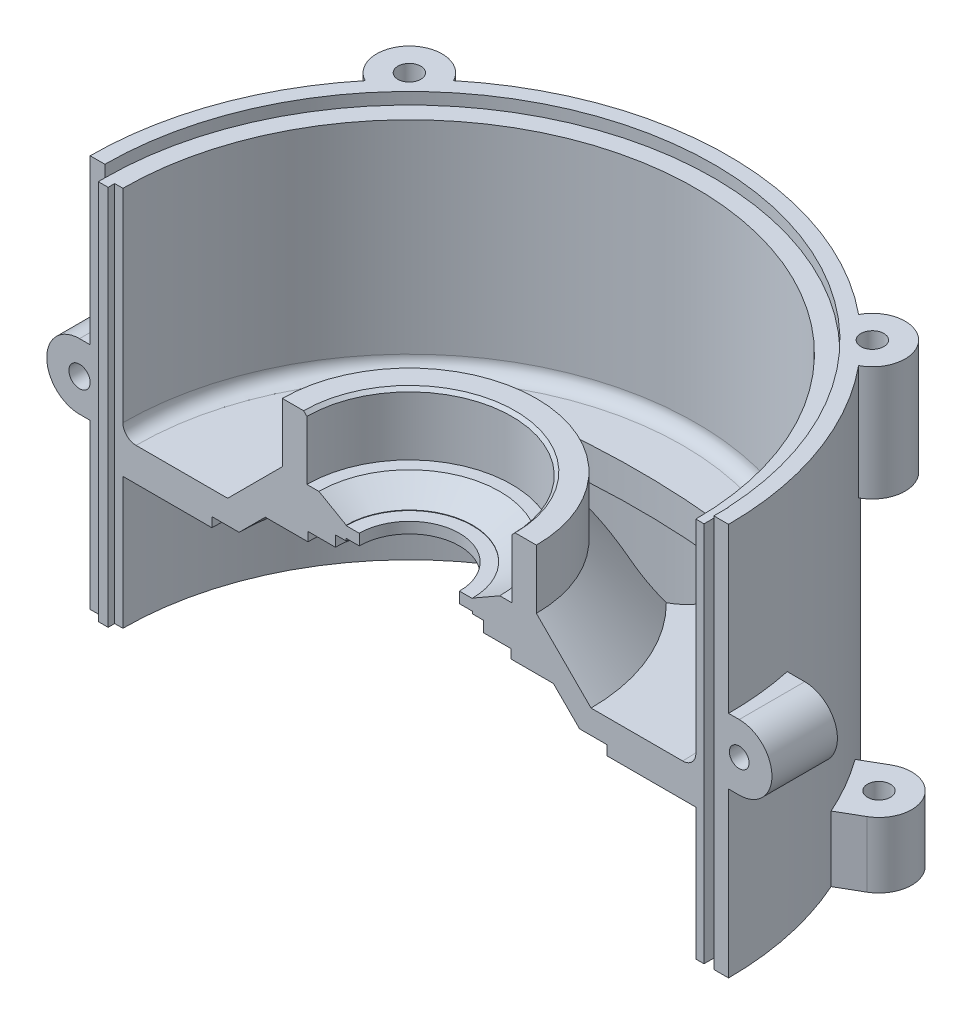
from build123d import *

# Parameters (mm, degrees)
REVOLU_O2_ANGLE          = 180
ESBO_O4_R                = 10
RESSALTO_EXTRUS_O1_DEPTH = 35
RESSALTO_EXTRUS_O2_DEPTH = 20
ESBO_O8_R                = 3.5
CORTE_EXTRUS_O2_DEPTH    = 20
PADR_OCIRCULAR1_COUNT    = 6
ESBO_O6_R                = 3.5
CORTE_EXTRUS_O1_DEPTH    = 15
ESBO_O9_R                = 1.25
CORTE_EXTRUS_O3_DEPTH    = 6
ESBO_O10_W               = 3
ESBO_O10_H               = 120
CORTE_EXTRUS_O4_DEPTH    = 4.5
ESBO_O11_W               = 3
ESBO_O11_H               = 116.4
RESSALTO_EXTRUS_O5_DEPTH = 2
ESBO_O12_R               = 3.25
RESSALTO_EXTRUS_O6_DEPTH = 20
ESBO_O13_R               = 3
RESSALTO_EXTRUS_O7_DEPTH = 20
CORTE_EXTRUS_O5_DEPTH    = 80.8
ESBO_O16_R               = 93
CORTE_EXTRUS_O6_DEPTH    = 10


with BuildPart() as part:
    # Esboço3 → Revolução2 (revolve)
    with BuildSketch(Plane.XY):
        with BuildLine():
            Line((97.5, 79.8), (97.5, 11.304491341))
            Line((97.5, 11.304491341), (97.5, 0))
            Line((97.5, 0), (97.5, -40.2))
            Line((97.5, -40.2), (87.5, -40.2))
            Line((87.5, -40.2), (87.5, 0))
            Line((87.5, 0), (60.342408243, 0))
            Line((60.342408243, 0), (60.342408243, 2.95))
            Line((60.342408243, 2.95), (52, 2.95))
            Line((52, 2.95), (44, 10.95))
            Line((44, 10.95), (31, 10.95))
            Line((31, 10.95), (31, 13.7))
            Line((31, 13.7), (22.6, 13.7))
            Line((22.6, 13.7), (22.6, 17))
            Line((22.6, 17), (19.3, 17))
            Line((19.3, 17), (19.3, 17.7))
            Line((19.3, 17.7), (15.3, 17.7))
            Line((15.3, 17.7), (15.3, 21.05))
            Line((15.3, 21.05), (19.3, 21.05))
            Line((19.3, 21.05), (19.3, 21.2))
            Line((19.3, 21.2), (27.626549127, 25.96))
            Line((27.626549127, 25.96), (31.3, 25.96))
            Line((31.3, 25.96), (31.3, 43.96))
            Line((31.3, 43.96), (32.3, 44.96))
            Line((32.3, 44.96), (38.8, 44.96))
            Line((38.8, 44.96), (38.8, 26.9))
            Line((38.8, 26.9), (55.5, 10.2))
            Line((55.5, 10.2), (83.5, 10.2))
            ThreePointArc((83.5, 10.2), (86.328427125, 11.371572875), (87.5, 14.2))
            Line((87.5, 14.2), (87.5, 76.2))
            Line((87.5, 76.2), (93, 76.2))
            Line((93, 76.2), (93, 79.8))
            Line((93, 79.8), (97.5, 79.8))
        make_face()
    revolve(axis=Axis((0, -3.322055656, 0), (0, 1, 0)), revolution_arc=REVOLU_O2_ANGLE)

    # Esboço4 → Ressalto-extrusão1 (add)
    with BuildSketch(Plane(origin=(0, 79.8, 0), x_dir=(1, 0, 0), z_dir=(0, 1, 0))):
        with Locations((70.71, 70.71)):
            Circle(ESBO_O4_R)
        with Locations((-70.71, 70.71)):
            Circle(ESBO_O4_R)
    extrude(amount=-RESSALTO_EXTRUS_O1_DEPTH)

    # Esboço5 → Ressalto-extrusão2 (add)
    with BuildSketch(Plane.XZ.offset(40.2)):
        with BuildLine():
            Line((10, -105), (10, -96.985823706))
            Line((10, -96.985823706), (-10, -96.985823706))
            Line((-10, -96.985823706), (-10, -105))
            ThreePointArc((-10, -105), (0, -115), (10, -105))
        make_face()
    ressalto_extrus_o2 = extrude(amount=-RESSALTO_EXTRUS_O2_DEPTH)

    # Esboço8 → Corte-extrusão2 (cut)
    with BuildSketch(Plane.XZ.offset(40.2)):
        with Locations((0, -105)):
            Circle(ESBO_O8_R)
    corte_extrus_o2 = extrude(amount=-CORTE_EXTRUS_O2_DEPTH, mode=Mode.SUBTRACT)

    # PadrãoCircular1: Ressalto-extrusão2, Corte-extrusão2 ×6 about axis, 3 skipped
    padr_ocircular1_axis = Axis((0, 0, 0), (0, 1, 0))
    add([ressalto_extrus_o2.rotate(padr_ocircular1_axis, i * 360 / PADR_OCIRCULAR1_COUNT) for i in range(1, PADR_OCIRCULAR1_COUNT) if i not in (2, 3, 4)])
    add([corte_extrus_o2.rotate(padr_ocircular1_axis, i * 360 / PADR_OCIRCULAR1_COUNT) for i in range(1, PADR_OCIRCULAR1_COUNT) if i not in (2, 3, 4)], mode=Mode.SUBTRACT)

    # Esboço6 → Corte-extrusão1 (cut)
    with BuildSketch(Plane(origin=(0, 79.8, 0), x_dir=(1, 0, 0), z_dir=(0, 1, 0))):
        with Locations((70.71, 70.71)):
            Circle(ESBO_O6_R)
        with Locations((-70.71, 70.71)):
            Circle(ESBO_O6_R)
    extrude(amount=-CORTE_EXTRUS_O1_DEPTH, mode=Mode.SUBTRACT)

    # Esboço9 → Corte-extrusão3 (cut)
    with BuildSketch(Plane.XZ.offset(-13.7)):
        with Locations((18.738329701, -18.738329701)):
            Circle(ESBO_O9_R)
        with Locations((-18.738329701, -18.738329701)):
            Circle(ESBO_O9_R)
    extrude(amount=-CORTE_EXTRUS_O3_DEPTH, mode=Mode.SUBTRACT)

    # Esboço10 → Corte-extrusão4 (cut)
    with BuildSketch(Plane.XY):
        with Locations((91.5, 19.8)):
            Rectangle(ESBO_O10_W, ESBO_O10_H)
    extrude(amount=-CORTE_EXTRUS_O4_DEPTH, mode=Mode.SUBTRACT)

    # Esboço11 → Ressalto-extrusão5 (add)
    with BuildSketch(Plane.XY):
        with Locations((-91.5, 18)):
            Rectangle(ESBO_O11_W, ESBO_O11_H)
    extrude(amount=RESSALTO_EXTRUS_O5_DEPTH)

    # Esboço12 → Ressalto-extrusão6 (add)
    with BuildSketch(Plane.XY):
        with BuildLine():
            Line((-100.75, 29.8), (-87.5, 29.8))
            Line((-87.5, 29.8), (-87.5, 9.8))
            Line((-87.5, 9.8), (-100.75, 9.8))
            ThreePointArc((-100.75, 9.8), (-110.75, 19.8), (-100.75, 29.8))
        make_face()
        with Locations((-100.75, 19.8)):
            Circle(ESBO_O12_R, mode=Mode.SUBTRACT)
    extrude(amount=-RESSALTO_EXTRUS_O6_DEPTH)

    # Esboço13 → Ressalto-extrusão7 (add)
    with BuildSketch(Plane.XY):
        with BuildLine():
            Line((100.75, 29.8), (93, 29.8))
            Line((93, 29.8), (93, 9.8))
            Line((93, 9.8), (100.75, 9.8))
            ThreePointArc((100.75, 9.8), (110.75, 19.8), (100.75, 29.8))
        make_face()
        with Locations((100.75, 19.8)):
            Circle(ESBO_O13_R, mode=Mode.SUBTRACT)
    extrude(amount=-RESSALTO_EXTRUS_O7_DEPTH)

    # Esboço14 → Corte-extrusão5 (cut, through all)
    with BuildSketch(Plane(origin=(0, 0, 0), x_dir=(-1, 0, 0), z_dir=(0, -1, 0))):
        with BuildLine():
            ThreePointArc((34.350508428, 67.496062714), (0, 70), (-34.350508428, 67.496062714))
            ThreePointArc((-34.350508428, 67.496062714), (-47.016691783, 50.479370931), (-30, 37.813187576))
            ThreePointArc((-30, 37.813187576), (0, 40), (30, 37.813187576))
            ThreePointArc((30, 37.813187576), (47.016691783, 50.479370931), (34.350508428, 67.496062714))
        make_face()
    extrude(amount=-CORTE_EXTRUS_O5_DEPTH, mode=Mode.SUBTRACT)

    # Esboço16 → Corte-extrusão6 (cut)
    with BuildSketch(Plane(origin=(0, 76.2, 0), x_dir=(1, 0, 0), z_dir=(0, 1, 0))):
        Circle(ESBO_O16_R)
    extrude(amount=CORTE_EXTRUS_O6_DEPTH, mode=Mode.SUBTRACT)


solid = part.part
